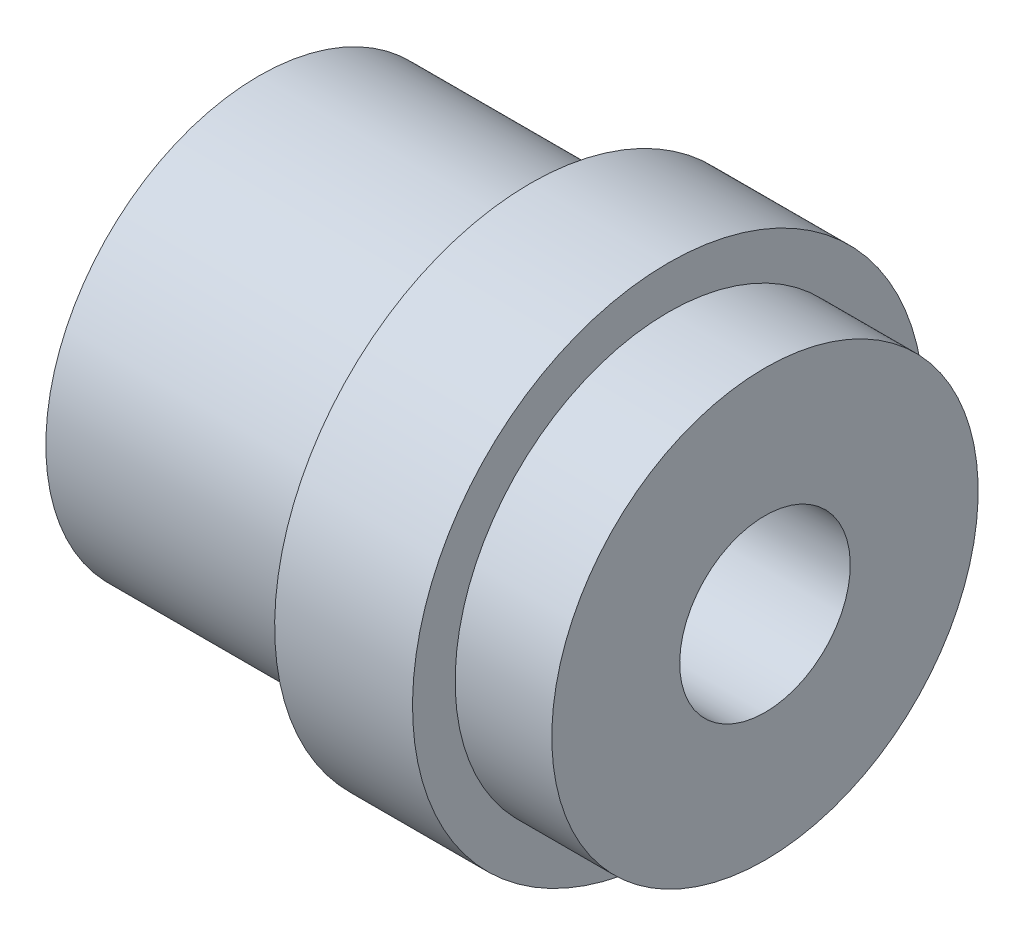
from build123d import *

# Parameters (mm, degrees)
SKETCH2_R          = 3
CUT_EXTRUDE1_DEPTH = 18.8


with BuildPart() as part:
    # Sketch1 → Revolve1 (revolve)
    with BuildSketch(Plane.XY):
        Polygon((-17.8, 0), (-17.8, 7.5), (-8.25, 7.5), (-8.25, 9), (-3.4, 9), (-3.4, 7.5), (0, 7.5), (0, 0), align=None)
    revolve(axis=Axis((0, 0, 0), (-1, 0, 0)))

    # Sketch2 → Cut-Extrude1 (cut, through all)
    with BuildSketch(Plane.ZY.offset(17.8)):
        Circle(SKETCH2_R)
    extrude(amount=-CUT_EXTRUDE1_DEPTH, mode=Mode.SUBTRACT)


solid = part.part
